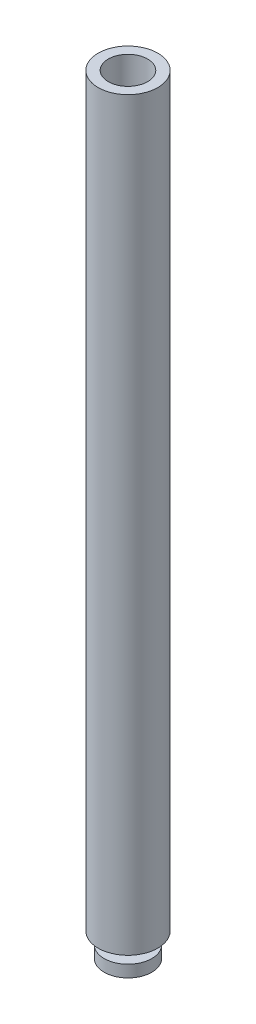
from build123d import *

# Parameters (mm, degrees)
SKETCH1_R           = 2.5
BOSS_EXTRUDE1_DEPTH = 62.5
SKETCH1_3_R         = 2
BOSS_EXTRUDE2_DEPTH = 1
SKETCH5_R           = 1
BOSS_EXTRUDE3_DEPTH = 1
SKETCH6_R           = 2
BOSS_EXTRUDE4_DEPTH = 1
SKETCH12_R          = 1.65
CUT_EXTRUDE1_DEPTH  = 5


with BuildPart() as part:
    # Sketch1 → Boss-Extrude1 (new body)
    with BuildSketch(Plane(origin=(0, 0, 0), x_dir=(1, 0, 0), z_dir=(0, 1, 0))):
        with Locations((-0.522013312, 0.511138034)):
            Circle(SKETCH1_R)
    extrude(amount=BOSS_EXTRUDE1_DEPTH)

    # Sketch1_3 → Boss-Extrude2 (add)
    with BuildSketch(Plane(origin=(0, 0, 0), x_dir=(1, 0, 0), z_dir=(0, 1, 0))):
        with Locations((-0.522013312, 0.511138034)):
            Circle(SKETCH1_3_R)
    extrude(amount=BOSS_EXTRUDE2_DEPTH)

    # Sketch5 → Boss-Extrude3 (add)
    with BuildSketch(Plane.XZ):
        with Locations((-0.522013312, -0.511138034)):
            Circle(SKETCH5_R)
    extrude(amount=BOSS_EXTRUDE3_DEPTH)

    # Sketch6 → Boss-Extrude4 (add)
    with BuildSketch(Plane.XZ.offset(1)):
        with Locations((-0.522013312, -0.511138034)):
            Circle(SKETCH6_R)
    extrude(amount=BOSS_EXTRUDE4_DEPTH)

    # Sketch12 → Cut-Extrude1 (cut)
    with BuildSketch(Plane(origin=(0, 62.5, 0), x_dir=(1, 0, 0), z_dir=(0, 1, 0))):
        with Locations((-0.522013312, 0.511138034)):
            Circle(SKETCH12_R)
    extrude(amount=-CUT_EXTRUDE1_DEPTH, mode=Mode.SUBTRACT)


solid = part.part
